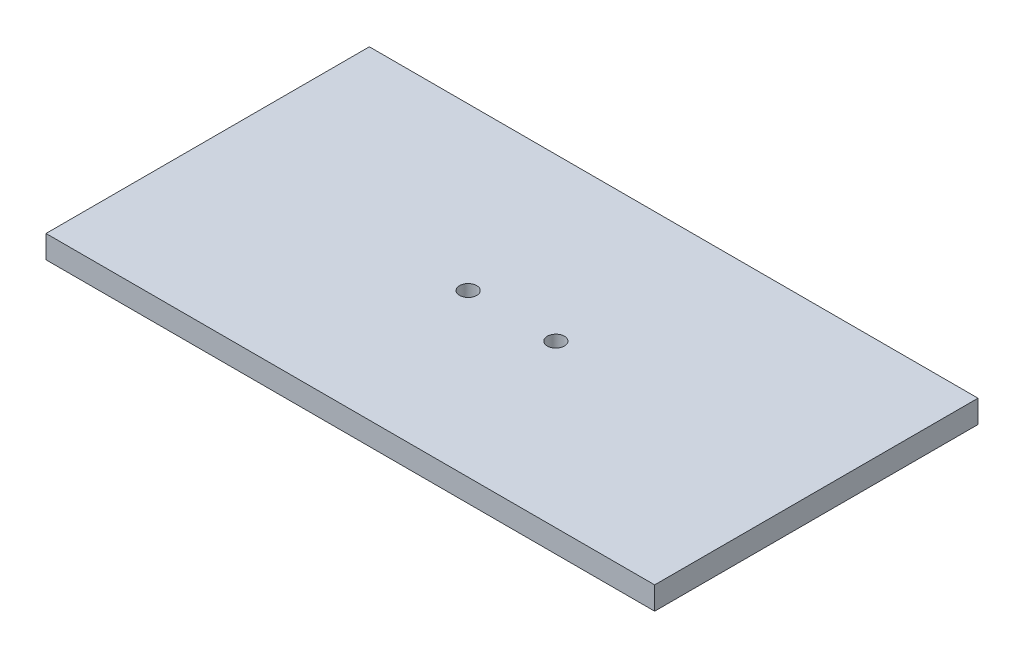
from build123d import *

# Parameters (mm, degrees)
ESBO_O1_W                  = 320
ESBO_O1_H                  = 170
RESSALTO_EXTRUS_O1_DEPTH   = 12
ESBO_O2_R                  = 4.5
CORTE_EXTRUS_O1_DEPTH      = 1
CORTE_EXTRUS_O1_DEPTH_BACK = 13


with BuildPart() as part:
    # Esboço1 → Ressalto-extrusão1 (new body)
    with BuildSketch(Plane(origin=(0, 0, 0), x_dir=(1, 0, 0), z_dir=(0, 1, 0))):
        Rectangle(ESBO_O1_W, ESBO_O1_H)
    extrude(amount=RESSALTO_EXTRUS_O1_DEPTH)

    # Esboço2 → Corte-extrusão1 (cut, two sides)
    with BuildSketch(Plane(origin=(0, 12, 0), x_dir=(1, 0, 0), z_dir=(0, 1, 0))) as corte_extrus_o1_sk:
        with Locations((-23.05, 0)):
            Circle(ESBO_O2_R)
        with Locations((23.05, 0)):
            Circle(ESBO_O2_R)
    extrude(amount=CORTE_EXTRUS_O1_DEPTH, mode=Mode.SUBTRACT)
    extrude(corte_extrus_o1_sk.sketch, amount=-CORTE_EXTRUS_O1_DEPTH_BACK, mode=Mode.SUBTRACT)


solid = part.part
